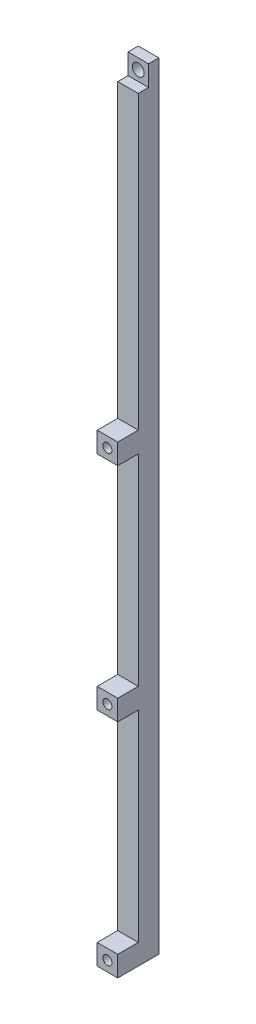
from build123d import *

# Parameters (mm, degrees)
SKETCH1_W                  = 6.35
SKETCH1_H                  = 12.7
BOSS_EXTRUDE1_DEPTH        = 240.03
CUT_EXTRUDE_THIN1_DEPTH    = 241.449606779
F_35_0_11_DIAMETER_HOLE1_D = 2.794
F_6_CLEARANCE_HOLE1_D      = 3.6576


with BuildPart() as part:
    # Sketch1 → Boss-Extrude1 (new body)
    with BuildSketch(Plane(origin=(0, 0, 0), x_dir=(1, 0, 0), z_dir=(0, 1, 0))):
        with Locations((3.175, 6.35)):
            Rectangle(SKETCH1_W, SKETCH1_H)
    extrude(amount=BOSS_EXTRUDE1_DEPTH)

    # Sketch2 → Cut-Extrude-Thin1 (cut, through all)
    with BuildSketch(Plane.ZY):
        Polygon((0, 233.68), (-9.525, 233.68), (-9.525, 240.03), (-9.52510033, 240.03), (-9.52510033, 233.67989967), (0, 233.67989967), align=None)
        Polygon((0, 143.51), (-6.35, 143.51), (-6.35, 233.68), (-6.35010033, 233.68), (-6.35010033, 143.50989967), (0, 143.50989967), align=None)
        Polygon((0, 137.16), (-6.35, 137.16), (-6.35, 74.93), (0, 74.93), (0, 74.93010033), (-6.34989967, 74.93010033), (-6.34989967, 137.15989967), (0, 137.15989967), align=None)
        Polygon((0, 68.58), (-6.35, 68.58), (-6.35, 6.35), (0, 6.35), (0, 6.35010033), (-6.34989967, 6.35010033), (-6.34989967, 68.57989967), (0, 68.57989967), align=None)
    extrude(amount=-CUT_EXTRUDE_THIN1_DEPTH, mode=Mode.SUBTRACT)


with BuildPart() as cut_extrude_thin1_kept_piece:
    # of the separate pieces the step leaves, the one the design keeps (cut_extrude_thin1_pieces_kept)
    add(part.part.solids().sort_by_distance((0, 0, 0))[0])

    # #35 (0.11) Diameter Hole1 (through all)
    with Locations(Plane.XY):
        with Locations((3.175, 140.335), (3.175, 71.755), (3.175, 3.174949835)):
            Hole(F_35_0_11_DIAMETER_HOLE1_D / 2)

    # #6 Clearance Hole1 (through all)
    with Locations(Plane.XY.offset(-9.52510033)):
        with Locations((3.175, 236.854949835)):
            Hole(F_6_CLEARANCE_HOLE1_D / 2)


solid = cut_extrude_thin1_kept_piece.part
